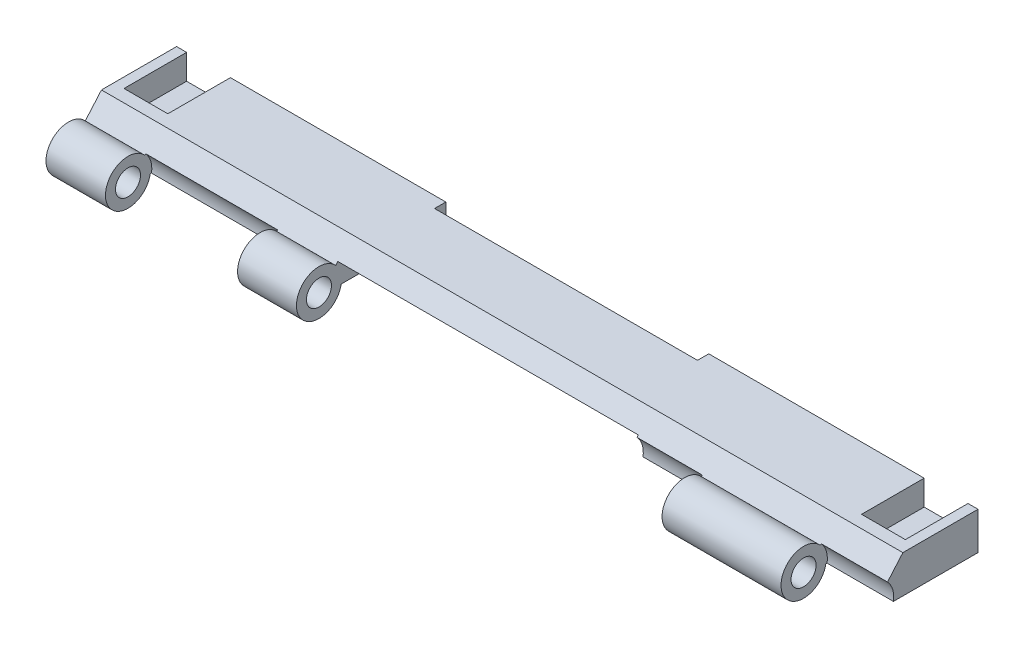
from build123d import *

# Parameters (mm, degrees)
SKETCH1_R                = 1.6002
SKETCH1_R_2              = 0.8128
BOSS_EXTRUDE5_DEPTH      = 162.56
CUT_EXTRUDE1_DEPTH       = 14.351
SKETCH3_W                = 0.889
SKETCH3_H                = 5.842
BOSS_EXTRUDE6_DEPTH      = 36.957
SKETCH16_W               = 13.462
SKETCH16_H               = 6.460130881
BOSS_EXTRUDE7_DEPTH      = 33.02
CUT_EXTRUDE4_DEPTH       = 15.24
SKETCH18_W               = 1.778
SKETCH18_H               = 5.842
BOSS_EXTRUDE8_DEPTH      = 38.1
CUT_EXTRUDE5_DEPTH       = 14.224
SKETCH20_W               = 2.1336
SKETCH20_H               = 5.461
BOSS_EXTRUDE9_DEPTH      = 36.322
SKETCH22_R               = 1.4224
CUT_EXTRUDE7_DEPTH       = 20.32
CUT_EXTRUDE7_DEPTH_BACK  = 24.13
SKETCH25_W               = 112.268
SKETCH25_H               = 3.007323321
CUT_EXTRUDE8_DEPTH       = 24.13
SKETCH27_R               = 1.778
CUT_EXTRUDE9_DEPTH       = 112.268
CUT_EXTRUDE12_DEPTH      = 14.224
SKETCH34_W               = 43.053
SKETCH34_H               = 2.1336
BOSS_EXTRUDE14_DEPTH     = 7.112
SKETCH35_R               = 1.4224
CUT_EXTRUDE13_DEPTH      = 7.112
SKETCH37_W               = 60.96
SKETCH37_H               = 15.24
CUT_EXTRUDE14_DEPTH      = 3.048
SKETCH38_R               = 0.8128
CUT_EXTRUDE15_DEPTH      = 5.08
SKETCH39_R               = 0.8128
CUT_EXTRUDE16_DEPTH      = 5.08
SKETCH40_W               = 60.96
SKETCH40_H               = 2.54
CUT_EXTRUDE17_DEPTH      = 3.048
SKETCH41_R               = 1.161307013
BOSS_EXTRUDE15_DEPTH     = 6.604
SKETCH42_R               = 1.020818471
BOSS_EXTRUDE16_DEPTH     = 5.588
SKETCH43_R               = 0.8128
CUT_EXTRUDE18_DEPTH      = 5.08
SKETCH44_R               = 0.8128
CUT_EXTRUDE19_DEPTH      = 5.08
SKETCH46_W               = 60.96
SKETCH46_H               = 9.087986699
CUT_EXTRUDE21_DEPTH      = 3.048
SKETCH47_W               = 53.34
SKETCH47_H               = 2.286
CUT_EXTRUDE22_DEPTH      = 15.24
SKETCH48_R               = 2.54
BOSS_EXTRUDE17_DEPTH     = 25.146
SKETCH49_R               = 2.54
BOSS_EXTRUDE18_DEPTH     = 25.146
SKETCH50_R               = 2.794
CUT_EXTRUDE23_DEPTH      = 112.268
SKETCH51_R               = 1.27
CUT_EXTRUDE24_DEPTH      = 174.498
CUT_EXTRUDE25_DEPTH      = 1.27
SKETCH55_W               = 46.703523857
SKETCH55_H               = 5.873481267
CUT_EXTRUDE26_DEPTH      = 9.144
CUT_EXTRUDE26_DEPTH_BACK = 8.636
SKETCH57_R               = 1.029255476
BOSS_EXTRUDE20_DEPTH     = 5.08
SKETCH58_R               = 1.09273592
BOSS_EXTRUDE21_DEPTH     = 7.112
SKETCH59_R               = 1.016
CUT_EXTRUDE27_DEPTH      = 66.04
CUT_EXTRUDE27_DEPTH_BACK = 5.08
SKETCH60_R               = 1.869467668
SKETCH60_R_2             = 1.016
BOSS_EXTRUDE22_DEPTH     = 162.56
SKETCH61_R               = 2.219373527
CUT_EXTRUDE28_DEPTH      = 112.268
SKETCH62_R               = 1.016
BOSS_EXTRUDE26_DEPTH     = 25.654
SKETCH65_R               = 1.016
BOSS_EXTRUDE27_DEPTH     = 25.654
SKETCH67_R               = 2.794
CUT_EXTRUDE32_DEPTH      = 12.827
SKETCH68_R               = 2.794
CUT_EXTRUDE33_DEPTH      = 12.827
SKETCH72_R               = 2.794
CUT_EXTRUDE34_DEPTH      = 25.654
BOSS_EXTRUDE28_DEPTH     = 0.127
SKETCH77_R               = 1.016
BOSS_EXTRUDE29_DEPTH     = 0.254
SKETCH79_R               = 1.016
CUT_EXTRUDE35_DEPTH      = 15.748
SKETCH87_W               = 23.622
SKETCH87_H               = 13.462
BOSS_EXTRUDE30_DEPTH     = 6.096
CUT_EXTRUDE36_DEPTH      = 14.9098
SKETCH89_W               = 1.4478
SKETCH89_H               = 6.35
BOSS_EXTRUDE31_DEPTH     = 30.6578
BOSS_EXTRUDE32_DEPTH     = 2.159
BOSS_EXTRUDE33_DEPTH     = 2.159
CUT_EXTRUDE38_DEPTH      = 43.053
BOSS_EXTRUDE35_DEPTH     = 14.859
SKETCH98_W               = 13.462
SKETCH98_H               = 6.35
CUT_EXTRUDE41_DEPTH      = 19.431
BOSS_EXTRUDE36_DEPTH     = 15.113
SKETCH102_W              = 13.462
SKETCH102_H              = 6.35
CUT_EXTRUDE42_DEPTH      = 27.051
BOSS_EXTRUDE39_DEPTH     = 2.159
BOSS_EXTRUDE40_DEPTH     = 14.986
BOSS_EXTRUDE41_DEPTH     = 2.159
SKETCH107_R              = 5.08
CUT_EXTRUDE43_DEPTH      = 173.736
SKETCH108_R              = 4.572
SKETCH108_R_2            = 2.54
BOSS_EXTRUDE43_DEPTH     = 162.56
SKETCH111_R              = 5.08
CUT_EXTRUDE44_DEPTH      = 60.96
SKETCH112_R              = 4.826
CUT_EXTRUDE45_DEPTH      = 13.462
SKETCH114_R              = 4.826
CUT_EXTRUDE46_DEPTH      = 26.797
SKETCH116_R              = 4.826
CUT_EXTRUDE47_DEPTH      = 13.208
SKETCH125_R              = 1.016
BOSS_EXTRUDE44_DEPTH     = 8.001
SKETCH126_R              = 1.016
BOSS_EXTRUDE45_DEPTH     = 7.747
SKETCH127_W              = 43.18
SKETCH127_H              = 1.27
BOSS_EXTRUDE46_DEPTH     = 1.27
SKETCH129_W              = 13.462
SKETCH129_H              = 6.35
BOSS_EXTRUDE47_DEPTH     = 47.244
SKETCH130_W              = 12.904618135
SKETCH130_H              = 7.62
BOSS_EXTRUDE48_DEPTH     = 46.482
SKETCH131_W              = 8.89
SKETCH131_H              = 12.7
CUT_EXTRUDE48_DEPTH      = 5.08


with BuildPart() as part:
    # Sketch1 → Boss-Extrude5 (new body)
    with BuildSketch(Plane(origin=(0, 0, 0), x_dir=(0, 0, -1), z_dir=(1, 0, 0))):
        with BuildLine():
            ThreePointArc((11.4584801, -1.874600251), (11.409460099, -2.267640517), (11.265403421, -2.636600251))
            Line((11.265403421, -2.636600251), (11.4584801, -2.636600251))
            Line((11.4584801, -2.636600251), (31.7784801, -2.636600251))
            Line((31.7784801, -2.636600251), (31.7784801, 4.983399749))
            Line((31.7784801, 4.983399749), (16.5384801, 4.983399749))
            Line((16.5384801, 4.983399749), (11.265403421, -1.112600251))
            ThreePointArc((11.265403421, -1.112600251), (11.409460099, -1.481559985), (11.4584801, -1.874600251))
        make_face()
        with Locations((9.8582801, -1.874600251)):
            Circle(SKETCH1_R)
        with Locations((9.8582801, -1.874600251)):
            Circle(SKETCH1_R_2, mode=Mode.SUBTRACT)
    extrude(amount=BOSS_EXTRUDE5_DEPTH)

    # Sketch2 → Cut-Extrude1 (cut)
    with BuildSketch(Plane(origin=(0, 0, -31.7784801), x_dir=(-1, 0, 0), z_dir=(0, 0, -1))):
        Polygon((0, 4.983399749), (0, -0.858600251), (-17.78, -0.858600251), (-23.622, 4.983399749), align=None)
    extrude(amount=-CUT_EXTRUDE1_DEPTH, mode=Mode.SUBTRACT)

    # Sketch3 → Boss-Extrude6 (add)
    with BuildSketch(Plane.ZY):
        with Locations((-31.3339801, 2.062399749)):
            Rectangle(SKETCH3_W, SKETCH3_H)
    extrude(amount=-BOSS_EXTRUDE6_DEPTH)

    # Sketch16 → Boss-Extrude7 (add)
    with BuildSketch(Plane.ZY):
        with Locations((-24.1584801, 1.753334308)):
            Rectangle(SKETCH16_W, SKETCH16_H)
    extrude(amount=-BOSS_EXTRUDE7_DEPTH)

    # Sketch17 → Cut-Extrude4 (cut)
    with BuildSketch(Plane(origin=(0, 0, -31.7784801), x_dir=(-1, 0, 0), z_dir=(0, 0, -1))):
        Polygon((0, 4.983399749), (0, -0.858600251), (-17.78, -0.858600251), (-23.622, 4.983399749), align=None)
    extrude(amount=-CUT_EXTRUDE4_DEPTH, mode=Mode.SUBTRACT)

    # Sketch18 → Boss-Extrude8 (add)
    with BuildSketch(Plane.ZY):
        with Locations((-30.8894801, 2.062399749)):
            Rectangle(SKETCH18_W, SKETCH18_H)
    extrude(amount=-BOSS_EXTRUDE8_DEPTH)

    # Sketch19 → Cut-Extrude5 (cut)
    with BuildSketch(Plane(origin=(0, 0, -31.7784801), x_dir=(-1, 0, 0), z_dir=(0, 0, -1))):
        Polygon((-162.56, 4.983399749), (-162.56, -0.477600251), (-142.24, -0.477600251), (-136.779, 4.983399749), align=None)
    extrude(amount=-CUT_EXTRUDE5_DEPTH, mode=Mode.SUBTRACT)

    # Sketch20 → Boss-Extrude9 (add)
    with BuildSketch(Plane(origin=(162.56, 0, 0), x_dir=(0, 0, -1), z_dir=(1, 0, 0))):
        with Locations((30.7116801, 2.252899749)):
            Rectangle(SKETCH20_W, SKETCH20_H)
    extrude(amount=-BOSS_EXTRUDE9_DEPTH)

    # Sketch22 → Cut-Extrude7 (cut, two sides)
    with BuildSketch(Plane(origin=(0, -0.477600251, 0), x_dir=(1, 0, 0), z_dir=(0, 1, 0))) as cut_extrude7_sk:
        with Locations((145.9484, 26.5714801)):
            Circle(SKETCH22_R)
        with BuildLine():
            ThreePointArc((147.3708, 26.5714801), (146.954188686, 25.565691415), (145.9484, 25.1490801))
            Line((145.9484, 25.1490801), (157.217057139, 25.1490801))
            ThreePointArc((157.217057139, 25.1490801), (155.794657139, 26.5714801), (157.217057139, 27.9938801))
            Line((157.217057139, 27.9938801), (145.9484, 27.9938801))
            ThreePointArc((145.9484, 27.9938801), (146.954188686, 27.577268786), (147.3708, 26.5714801))
        make_face()
        with Locations((157.217057139, 26.5714801)):
            Circle(SKETCH22_R)
        with BuildLine():
            ThreePointArc((157.217057139, 19.1292801), (155.794657139, 20.5516801), (157.217057139, 21.9740801))
            Line((157.217057139, 21.9740801), (145.9484, 21.9740801))
            ThreePointArc((145.9484, 21.9740801), (146.954188686, 21.557468786), (147.3708, 20.5516801))
            ThreePointArc((147.3708, 20.5516801), (146.954188686, 19.545891415), (145.9484, 19.1292801))
            Line((145.9484, 19.1292801), (157.217057139, 19.1292801))
        make_face()
        with Locations((157.217057139, 20.5516801)):
            Circle(SKETCH22_R)
        with Locations((145.9484, 20.5516801)):
            Circle(SKETCH22_R)
    extrude(amount=CUT_EXTRUDE7_DEPTH, mode=Mode.SUBTRACT)
    extrude(cut_extrude7_sk.sketch, amount=-CUT_EXTRUDE7_DEPTH_BACK, mode=Mode.SUBTRACT)

    # Sketch25 → Cut-Extrude8 (cut)
    with BuildSketch(Plane(origin=(0, 4.983399749, 0), x_dir=(1, 0, 0), z_dir=(0, 1, 0))):
        with Locations((81.28, 9.761741761)):
            Rectangle(SKETCH25_W, SKETCH25_H)
    extrude(amount=-CUT_EXTRUDE8_DEPTH, mode=Mode.SUBTRACT)

    # Sketch27 → Cut-Extrude9 (cut)
    with BuildSketch(Plane.ZY.offset(-137.414)):
        with Locations((-9.8582801, -1.874600251)):
            Circle(SKETCH27_R)
    extrude(amount=CUT_EXTRUDE9_DEPTH, mode=Mode.SUBTRACT)

    # Sketch31 → Cut-Extrude12 (cut)
    with BuildSketch(Plane(origin=(0, 0, -31.7784801), x_dir=(-1, 0, 0), z_dir=(0, 0, -1))):
        Polygon((-162.56, 4.983399749), (-162.56, -0.477600251), (-124.968, -0.477600251), (-119.507, 4.983399749), (-124.079, 4.983399749), align=None)
    extrude(amount=-CUT_EXTRUDE12_DEPTH, mode=Mode.SUBTRACT)

    # Sketch34 → Boss-Extrude14 (add)
    with BuildSketch(Plane(origin=(0, 4.983399749, 0), x_dir=(1, 0, 0), z_dir=(0, 1, 0))):
        with Locations((141.0335, 30.7116801)):
            Rectangle(SKETCH34_W, SKETCH34_H)
    extrude(amount=-BOSS_EXTRUDE14_DEPTH)

    # Sketch35 → Cut-Extrude13 (cut)
    with BuildSketch(Plane(origin=(0, -0.477600251, 0), x_dir=(1, 0, 0), z_dir=(0, 1, 0))):
        with BuildLine():
            Line((130.048, 25.1490801), (145.9484, 25.1490801))
            ThreePointArc((145.9484, 25.1490801), (144.526, 26.5714801), (145.9484, 27.9938801))
            Line((145.9484, 27.9938801), (130.048, 27.9938801))
            ThreePointArc((130.048, 27.9938801), (131.053788686, 27.577268786), (131.4704, 26.5714801))
            ThreePointArc((131.4704, 26.5714801), (131.053788686, 25.565691415), (130.048, 25.1490801))
        make_face()
        with BuildLine():
            ThreePointArc((145.9484, 19.1292801), (144.526, 20.5516801), (145.9484, 21.9740801))
            Line((145.9484, 21.9740801), (130.048, 21.9740801))
            ThreePointArc((130.048, 21.9740801), (131.053788686, 21.557468786), (131.4704, 20.5516801))
            ThreePointArc((131.4704, 20.5516801), (131.053788686, 19.545891415), (130.048, 19.1292801))
            Line((130.048, 19.1292801), (145.9484, 19.1292801))
        make_face()
        with Locations((130.048, 20.5516801)):
            Circle(SKETCH35_R)
        with Locations((130.048, 26.5714801)):
            Circle(SKETCH35_R)
    extrude(amount=-CUT_EXTRUDE13_DEPTH, mode=Mode.SUBTRACT)

    # Sketch37 → Cut-Extrude14 (cut)
    with BuildSketch(Plane(origin=(0, -2.636600251, 0), x_dir=(-1, 0, 0), z_dir=(0, -1, 0))):
        with Locations((-81.28, 21.6184801)):
            Rectangle(SKETCH37_W, SKETCH37_H)
    extrude(amount=-CUT_EXTRUDE14_DEPTH, mode=Mode.SUBTRACT)

    # Sketch38 → Cut-Extrude15 (cut)
    with BuildSketch(Plane.ZY.offset(-111.76)):
        with Locations((-27.9684801, -1.112600251)):
            Circle(SKETCH38_R)
    extrude(amount=-CUT_EXTRUDE15_DEPTH, mode=Mode.SUBTRACT)

    # Sketch39 → Cut-Extrude16 (cut)
    with BuildSketch(Plane(origin=(50.8, 0, 0), x_dir=(0, 0, -1), z_dir=(1, 0, 0))):
        with Locations(Location((27.9684801, -1.112600251, 0), (0, 0, 180))):
            Circle(SKETCH39_R)
    extrude(amount=-CUT_EXTRUDE16_DEPTH, mode=Mode.SUBTRACT)

    # Sketch40 → Cut-Extrude17 (cut)
    with BuildSketch(Plane(origin=(0, -2.636600251, 0), x_dir=(-1, 0, 0), z_dir=(0, -1, 0))):
        with Locations((-81.28, 30.5084801)):
            Rectangle(SKETCH40_W, SKETCH40_H)
    extrude(amount=-CUT_EXTRUDE17_DEPTH, mode=Mode.SUBTRACT)

    # Sketch41 → Boss-Extrude15 (add)
    with BuildSketch(Plane(origin=(50.8, 0, 0), x_dir=(0, 0, -1), z_dir=(1, 0, 0))):
        with Locations((27.9684801, -1.112600251)):
            Circle(SKETCH41_R)
    extrude(amount=-BOSS_EXTRUDE15_DEPTH)

    # Sketch42 → Boss-Extrude16 (add)
    with BuildSketch(Plane.ZY.offset(-111.76)):
        with Locations((-27.9684801, -1.112600251)):
            Circle(SKETCH42_R)
    extrude(amount=-BOSS_EXTRUDE16_DEPTH)

    # Sketch43 → Cut-Extrude18 (cut)
    with BuildSketch(Plane(origin=(50.8, 0, 0), x_dir=(0, 0, -1), z_dir=(1, 0, 0))):
        with Locations((30.5084801, -1.112600251)):
            Circle(SKETCH43_R)
    extrude(amount=-CUT_EXTRUDE18_DEPTH, mode=Mode.SUBTRACT)

    # Sketch44 → Cut-Extrude19 (cut)
    with BuildSketch(Plane.ZY.offset(-111.76)):
        with Locations(Location((-30.5084801, -1.112600251, 0), (0, 0, 180))):
            Circle(SKETCH44_R)
    extrude(amount=-CUT_EXTRUDE19_DEPTH, mode=Mode.SUBTRACT)

    # Sketch46 → Cut-Extrude21 (cut)
    with BuildSketch(Plane(origin=(0, -2.636600251, 0), x_dir=(-1, 0, 0), z_dir=(0, -1, 0))):
        with Locations((-81.28, 9.45448675)):
            Rectangle(SKETCH46_W, SKETCH46_H)
    extrude(amount=-CUT_EXTRUDE21_DEPTH, mode=Mode.SUBTRACT)

    # Sketch47 → Cut-Extrude22 (cut)
    with BuildSketch(Plane(origin=(0, 0.411399749, 0), x_dir=(-1, 0, 0), z_dir=(0, -1, 0))):
        with Locations((-81.28, 30.6354801)):
            Rectangle(SKETCH47_W, SKETCH47_H)
    extrude(amount=-CUT_EXTRUDE22_DEPTH, mode=Mode.SUBTRACT)

    # Sketch48 → Boss-Extrude17 (add)
    with BuildSketch(Plane.ZY):
        with Locations((-9.8582801, -1.874600251)):
            Circle(SKETCH48_R)
    extrude(amount=-BOSS_EXTRUDE17_DEPTH)

    # Sketch49 → Boss-Extrude18 (add)
    with BuildSketch(Plane(origin=(162.56, 0, 0), x_dir=(0, 0, -1), z_dir=(1, 0, 0))):
        with Locations((9.8582801, -1.874600251)):
            Circle(SKETCH49_R)
    extrude(amount=-BOSS_EXTRUDE18_DEPTH)

    # Sketch50 → Cut-Extrude23 (cut)
    with BuildSketch(Plane.ZY.offset(-137.414)):
        with Locations((-9.8582801, -1.874600251)):
            Circle(SKETCH50_R)
    extrude(amount=CUT_EXTRUDE23_DEPTH, mode=Mode.SUBTRACT)

    # Sketch51 → Cut-Extrude24 (cut)
    with BuildSketch(Plane(origin=(162.56, 0, 0), x_dir=(0, 0, -1), z_dir=(1, 0, 0))):
        with Locations((9.8582801, -1.874600251)):
            Circle(SKETCH51_R)
    extrude(amount=-CUT_EXTRUDE24_DEPTH, mode=Mode.SUBTRACT)

    # Sketch52 → Cut-Extrude25 (cut)
    with BuildSketch(Plane(origin=(0, 0.411399749, 0), x_dir=(-1, 0, 0), z_dir=(0, -1, 0))):
        Polygon((-50.8, 31.7784801), (-50.8, 12.546363432), (-111.76, 12.6522801), (-111.76, 31.7784801), align=None)
    extrude(amount=-CUT_EXTRUDE25_DEPTH, mode=Mode.SUBTRACT)

    # Sketch55 → Cut-Extrude26 (cut, two sides)
    with BuildSketch(Plane.XZ.offset(2.636600251)) as cut_extrude26_sk:
        with Locations((88.408238071, -10.745489599)):
            Rectangle(SKETCH55_W, SKETCH55_H)
    extrude(amount=CUT_EXTRUDE26_DEPTH, mode=Mode.SUBTRACT)
    extrude(cut_extrude26_sk.sketch, amount=-CUT_EXTRUDE26_DEPTH_BACK, mode=Mode.SUBTRACT)

    # Sketch57 → Boss-Extrude20 (add)
    with BuildSketch(Plane(origin=(45.72, 0, 0), x_dir=(0, 0, -1), z_dir=(1, 0, 0))):
        with Locations((30.5084801, -1.112600251)):
            Circle(SKETCH57_R)
    extrude(amount=BOSS_EXTRUDE20_DEPTH)

    # Sketch58 → Boss-Extrude21 (add)
    with BuildSketch(Plane.ZY.offset(-111.76)):
        with Locations((-30.5084801, -1.112600251)):
            Circle(SKETCH58_R)
    extrude(amount=-BOSS_EXTRUDE21_DEPTH)

    # Sketch59 → Cut-Extrude27 (cut, two sides)
    with BuildSketch(Plane(origin=(50.8, 0, 0), x_dir=(0, 0, -1), z_dir=(1, 0, 0))) as cut_extrude27_sk:
        with Locations((29.2384801, -0.477600251)):
            Circle(SKETCH59_R)
    extrude(amount=CUT_EXTRUDE27_DEPTH, mode=Mode.SUBTRACT)
    extrude(cut_extrude27_sk.sketch, amount=-CUT_EXTRUDE27_DEPTH_BACK, mode=Mode.SUBTRACT)

    # Sketch60 → Boss-Extrude22 (add)
    with BuildSketch(Plane.ZY):
        with Locations((-9.8582801, -1.874600251)):
            Circle(SKETCH60_R)
        with Locations((-9.8582801, -1.874600251)):
            Circle(SKETCH60_R_2, mode=Mode.SUBTRACT)
    extrude(amount=-BOSS_EXTRUDE22_DEPTH)

    # Sketch61 → Cut-Extrude28 (cut)
    with BuildSketch(Plane.ZY.offset(-137.414)):
        with Locations((-9.8582801, -1.874600251)):
            Circle(SKETCH61_R)
    extrude(amount=CUT_EXTRUDE28_DEPTH, mode=Mode.SUBTRACT)

    # Sketch62 → Boss-Extrude26 (add)
    with BuildSketch(Plane(origin=(25.146, 0, 0), x_dir=(0, 0, -1), z_dir=(1, 0, 0))):
        with BuildLine():
            Line((12.07614536, -0.175332853), (11.906096413, -0.371919863))
            ThreePointArc((11.906096413, -0.371919863), (12.272100043, -1.083984489), (12.3982801, -1.874600251))
            ThreePointArc((12.3982801, -1.874600251), (12.368861124, -2.260064807), (12.281285672, -2.636600251))
            Line((12.281285672, -2.636600251), (12.546363432, -2.636600251))
            ThreePointArc((12.546363432, -2.636600251), (12.602645637, -1.350297092), (12.07614536, -0.175332853))
        make_face()
        with BuildLine():
            ThreePointArc((12.3982801, -1.874600251), (12.272100043, -1.083984489), (11.906096413, -0.371919863))
            ThreePointArc((11.906096413, -0.371919863), (7.352435653, -2.289743123), (12.281285672, -2.636600251))
            ThreePointArc((12.281285672, -2.636600251), (12.368861124, -2.260064807), (12.3982801, -1.874600251))
        make_face()
        with Locations(Location((9.8582801, -1.874600251, 0), (0, 0, 180))):
            Circle(SKETCH62_R, mode=Mode.SUBTRACT)
    extrude(amount=BOSS_EXTRUDE26_DEPTH)

    # Sketch65 → Boss-Extrude27 (add)
    with BuildSketch(Plane.ZY.offset(-137.414)):
        with BuildLine():
            ThreePointArc((-12.281285672, -2.636600251), (-12.364124548, -1.459457379), (-11.906096413, -0.371919863))
            Line((-11.906096413, -0.371919863), (-12.07614536, -0.175332853))
            ThreePointArc((-12.07614536, -0.175332853), (-12.602645637, -1.350297092), (-12.546363432, -2.636600251))
            Line((-12.546363432, -2.636600251), (-12.281285672, -2.636600251))
        make_face()
        with BuildLine():
            ThreePointArc((-7.3182801, -1.874600251), (-9.067664339, 0.539219692), (-11.906096413, -0.371919863))
            ThreePointArc((-11.906096413, -0.371919863), (-12.364124548, -1.459457379), (-12.281285672, -2.636600251))
            ThreePointArc((-12.281285672, -2.636600251), (-9.472815544, -4.385181275), (-7.3182801, -1.874600251))
        make_face()
        with Locations((-9.8582801, -1.874600251)):
            Circle(SKETCH65_R, mode=Mode.SUBTRACT)
    extrude(amount=BOSS_EXTRUDE27_DEPTH)

    # Sketch67 → Cut-Extrude32 (cut)
    with BuildSketch(Plane(origin=(162.56, 0, 0), x_dir=(0, 0, -1), z_dir=(1, 0, 0))):
        with Locations((9.8582801, -1.874600251)):
            Circle(SKETCH67_R)
    extrude(amount=-CUT_EXTRUDE32_DEPTH, mode=Mode.SUBTRACT)

    # Sketch68 → Cut-Extrude33 (cut)
    with BuildSketch(Plane.ZY.offset(-111.76)):
        with Locations((-9.8582801, -1.874600251)):
            Circle(SKETCH68_R)
    extrude(amount=-CUT_EXTRUDE33_DEPTH, mode=Mode.SUBTRACT)

    # Sketch72 → Cut-Extrude34 (cut)
    with BuildSketch(Plane.ZY.offset(-12.573)):
        with Locations((-9.8582801, -1.874600251)):
            Circle(SKETCH72_R)
    extrude(amount=-CUT_EXTRUDE34_DEPTH, mode=Mode.SUBTRACT)

    # Sketch74 → Boss-Extrude28 (add)
    with BuildSketch(Plane.ZY.offset(-12.573)):
        with BuildLine():
            Line((-12.546363432, -2.636600251), (-12.281285672, -2.636600251))
            ThreePointArc((-12.281285672, -2.636600251), (-7.352435653, -2.289743123), (-11.906096413, -0.371919863))
            Line((-11.906096413, -0.371919863), (-12.07614536, -0.175332853))
            ThreePointArc((-12.07614536, -0.175332853), (-12.602645637, -1.350297092), (-12.546363432, -2.636600251))
        make_face()
    extrude(amount=-BOSS_EXTRUDE28_DEPTH)

    # Sketch77 → Boss-Extrude29 (add)
    with BuildSketch(Plane.ZY.offset(-124.587)):
        with BuildLine():
            ThreePointArc((-11.906096413, -0.371919863), (-12.364124548, -1.459457379), (-12.281285672, -2.636600251))
            ThreePointArc((-12.281285672, -2.636600251), (-9.472815544, -4.385181275), (-7.3182801, -1.874600251))
            ThreePointArc((-7.3182801, -1.874600251), (-9.067664339, 0.539219692), (-11.906096413, -0.371919863))
        make_face()
        with Locations((-9.8582801, -1.874600251)):
            Circle(SKETCH77_R, mode=Mode.SUBTRACT)
        with BuildLine():
            Line((-12.546363432, -2.636600251), (-12.281285672, -2.636600251))
            ThreePointArc((-12.281285672, -2.636600251), (-12.364124548, -1.459457379), (-11.906096413, -0.371919863))
            Line((-11.906096413, -0.371919863), (-12.07614536, -0.175332853))
            ThreePointArc((-12.07614536, -0.175332853), (-12.602645637, -1.350297092), (-12.546363432, -2.636600251))
        make_face()
    extrude(amount=BOSS_EXTRUDE29_DEPTH)

    # Sketch79 → Cut-Extrude35 (cut)
    with BuildSketch(Plane.ZY):
        with Locations((-9.8582801, -1.874600251)):
            Circle(SKETCH79_R)
    extrude(amount=-CUT_EXTRUDE35_DEPTH, mode=Mode.SUBTRACT)

    # Sketch87 → Boss-Extrude30 (add)
    with BuildSketch(Plane(origin=(0, 4.983399749, 0), x_dir=(1, 0, 0), z_dir=(0, 1, 0))):
        with Locations((11.811, 23.2694801)):
            Rectangle(SKETCH87_W, SKETCH87_H)
    extrude(amount=-BOSS_EXTRUDE30_DEPTH)

    # Sketch88 → Cut-Extrude36 (cut)
    with BuildSketch(Plane(origin=(0, 0, -31.7784801), x_dir=(-1, 0, 0), z_dir=(0, 0, -1))):
        Polygon((0, 4.983399749), (0, -1.366600251), (-17.78, -1.366600251), (-23.622, 4.983399749), align=None)
    extrude(amount=-CUT_EXTRUDE36_DEPTH, mode=Mode.SUBTRACT)

    # Sketch89 → Boss-Extrude31 (add)
    with BuildSketch(Plane.ZY):
        with Locations((-31.0545801, 1.808399749)):
            Rectangle(SKETCH89_W, SKETCH89_H)
    extrude(amount=-BOSS_EXTRUDE31_DEPTH)

    # Sketch90 → Boss-Extrude32 (add)
    with BuildSketch(Plane(origin=(0, -2.636600251, 0), x_dir=(-1, 0, 0), z_dir=(0, -1, 0))):
        with BuildLine():
            Line((-130.048, 27.9938801), (-137.16, 27.9938801))
            ThreePointArc((-137.16, 27.9938801), (-136.154211314, 27.577268786), (-135.7376, 26.5714801))
            ThreePointArc((-135.7376, 26.5714801), (-136.154211314, 25.565691415), (-137.16, 25.1490801))
            Line((-137.16, 25.1490801), (-130.048, 25.1490801))
            ThreePointArc((-130.048, 25.1490801), (-128.6256, 26.5714801), (-130.048, 27.9938801))
        make_face()
        with BuildLine():
            ThreePointArc((-135.7376, 20.5516801), (-136.154211314, 19.545891415), (-137.16, 19.1292801))
            Line((-137.16, 19.1292801), (-130.048, 19.1292801))
            ThreePointArc((-130.048, 19.1292801), (-128.6256, 20.5516801), (-130.048, 21.9740801))
            Line((-130.048, 21.9740801), (-137.16, 21.9740801))
            ThreePointArc((-137.16, 21.9740801), (-136.154211314, 21.557468786), (-135.7376, 20.5516801))
        make_face()
    extrude(amount=-BOSS_EXTRUDE32_DEPTH)

    # Sketch91 → Boss-Extrude33 (add)
    with BuildSketch(Plane(origin=(0, -2.636600251, 0), x_dir=(-1, 0, 0), z_dir=(0, -1, 0))):
        with BuildLine():
            Line((-156.251857139, 26.5714801), (-158.639457139, 26.5714801))
            ThreePointArc((-158.639457139, 26.5714801), (-158.222845825, 25.565691415), (-157.217057139, 25.1490801))
            Line((-157.217057139, 25.1490801), (-154.829457139, 25.1490801))
            ThreePointArc((-154.829457139, 25.1490801), (-155.835245825, 25.565691415), (-156.251857139, 26.5714801))
        make_face()
        with BuildLine():
            ThreePointArc((-157.217057139, 27.9938801), (-158.222845825, 27.577268786), (-158.639457139, 26.5714801))
            Line((-158.639457139, 26.5714801), (-156.251857139, 26.5714801))
            ThreePointArc((-156.251857139, 26.5714801), (-155.835245825, 27.577268786), (-154.829457139, 27.9938801))
            Line((-154.829457139, 27.9938801), (-157.217057139, 27.9938801))
        make_face()
        with BuildLine():
            ThreePointArc((-157.217057139, 21.9740801), (-158.222845825, 21.557468786), (-158.639457139, 20.5516801))
            Line((-158.639457139, 20.5516801), (-156.251857139, 20.5516801))
            ThreePointArc((-156.251857139, 20.5516801), (-155.835245825, 21.557468786), (-154.829457139, 21.9740801))
            Line((-154.829457139, 21.9740801), (-157.217057139, 21.9740801))
        make_face()
        with BuildLine():
            Line((-156.251857139, 20.5516801), (-158.639457139, 20.5516801))
            ThreePointArc((-158.639457139, 20.5516801), (-158.222845825, 19.545891415), (-157.217057139, 19.1292801))
            Line((-157.217057139, 19.1292801), (-154.829457139, 19.1292801))
            ThreePointArc((-154.829457139, 19.1292801), (-155.835245825, 19.545891415), (-156.251857139, 20.5516801))
        make_face()
    extrude(amount=-BOSS_EXTRUDE33_DEPTH)

    # Sketch92 → Cut-Extrude38 (cut)
    with BuildSketch(Plane(origin=(162.56, 0, 0), x_dir=(0, 0, -1), z_dir=(1, 0, 0))):
        Polygon((29.6448801, -0.477600251), (29.8988801, -0.477600251), (29.8988801, 4.983399749), (17.3004801, 4.983399749), (17.3004801, -0.477600251), align=None)
    extrude(amount=-CUT_EXTRUDE38_DEPTH, mode=Mode.SUBTRACT)

    # Sketch94 → Boss-Extrude35 (add)
    with BuildSketch(Plane(origin=(0, 0, -31.7784801), x_dir=(-1, 0, 0), z_dir=(0, 0, -1))):
        Polygon((-119.507, 4.983399749), (-124.968, -0.477600251), (-119.507, -0.477600251), align=None)
    extrude(amount=-BOSS_EXTRUDE35_DEPTH)

    # Sketch98 → Cut-Extrude41 (cut)
    with BuildSketch(Plane.ZY.offset(-23.622)):
        with Locations((-23.5996801, 1.808399749)):
            Rectangle(SKETCH98_W, SKETCH98_H)
    extrude(amount=-CUT_EXTRUDE41_DEPTH, mode=Mode.SUBTRACT)

    # Sketch101 → Boss-Extrude36 (add)
    with BuildSketch(Plane(origin=(0, 0, -31.7784801), x_dir=(-1, 0, 0), z_dir=(0, 0, -1))):
        Polygon((-43.053, 4.983399749), (-37.592, -0.477600251), (-43.053, -0.477600251), align=None)
    extrude(amount=-BOSS_EXTRUDE36_DEPTH)

    # Sketch102 → Cut-Extrude42 (cut)
    with BuildSketch(Plane.ZY):
        with Locations((-23.5996801, 1.808399749)):
            Rectangle(SKETCH102_W, SKETCH102_H)
    extrude(amount=-CUT_EXTRUDE42_DEPTH, mode=Mode.SUBTRACT)

    # Sketch103 → Boss-Extrude39 (add)
    with BuildSketch(Plane(origin=(0, -0.477600251, 0), x_dir=(1, 0, 0), z_dir=(0, 1, 0))):
        with BuildLine():
            ThreePointArc((137.7696, 26.5714801), (138.186211314, 27.577268786), (139.192, 27.9938801))
            Line((139.192, 27.9938801), (137.16, 27.9938801))
            ThreePointArc((137.16, 27.9938801), (135.7376, 26.5714801), (137.16, 25.1490801))
            Line((137.16, 25.1490801), (139.192, 25.1490801))
            ThreePointArc((139.192, 25.1490801), (138.186211314, 25.565691415), (137.7696, 26.5714801))
        make_face()
        with BuildLine():
            ThreePointArc((137.7696, 20.5516801), (138.186211314, 21.557468786), (139.192, 21.9740801))
            Line((139.192, 21.9740801), (137.16, 21.9740801))
            ThreePointArc((137.16, 21.9740801), (135.7376, 20.5516801), (137.16, 19.1292801))
            Line((137.16, 19.1292801), (139.192, 19.1292801))
            ThreePointArc((139.192, 19.1292801), (138.186211314, 19.545891415), (137.7696, 20.5516801))
        make_face()
    extrude(amount=-BOSS_EXTRUDE39_DEPTH)

    # Sketch105 → Boss-Extrude40 (add)
    with BuildSketch(Plane(origin=(0, 0, -31.7784801), x_dir=(-1, 0, 0), z_dir=(0, 0, -1))):
        Polygon((-43.053, 4.983399749), (-43.053, -2.200805148), (-35.868795103, -2.200805148), align=None)
    extrude(amount=-BOSS_EXTRUDE40_DEPTH)

    # Sketch106 → Boss-Extrude41 (add)
    with BuildSketch(Plane(origin=(0, -0.477600251, 0), x_dir=(1, 0, 0), z_dir=(0, 1, 0))):
        with BuildLine():
            ThreePointArc((154.432, 27.9938801), (155.437788686, 27.577268786), (155.8544, 26.5714801))
            ThreePointArc((155.8544, 26.5714801), (155.437788686, 25.565691415), (154.432, 25.1490801))
            Line((154.432, 25.1490801), (154.829457139, 25.1490801))
            ThreePointArc((154.829457139, 25.1490801), (156.251857139, 26.5714801), (154.829457139, 27.9938801))
            Line((154.829457139, 27.9938801), (154.432, 27.9938801))
        make_face()
        with BuildLine():
            ThreePointArc((154.432, 21.9740801), (155.437788686, 21.557468786), (155.8544, 20.5516801))
            ThreePointArc((155.8544, 20.5516801), (155.437788686, 19.545891415), (154.432, 19.1292801))
            Line((154.432, 19.1292801), (154.829457139, 19.1292801))
            ThreePointArc((154.829457139, 19.1292801), (156.251857139, 20.5516801), (154.829457139, 21.9740801))
            Line((154.829457139, 21.9740801), (154.432, 21.9740801))
        make_face()
    extrude(amount=-BOSS_EXTRUDE41_DEPTH)

    # Sketch107 → Cut-Extrude43 (cut)
    with BuildSketch(Plane(origin=(162.56, 0, 0), x_dir=(0, 0, -1), z_dir=(1, 0, 0))):
        with Locations((9.8582801, -1.874600251)):
            Circle(SKETCH107_R)
    extrude(amount=-CUT_EXTRUDE43_DEPTH, mode=Mode.SUBTRACT)

    # Sketch108 → Boss-Extrude43 (add)
    with BuildSketch(Plane.ZY):
        with BuildLine():
            Line((-13.25421048, 1.186582667), (-13.588864385, 1.573463104))
            ThreePointArc((-13.588864385, 1.573463104), (-14.714759103, -0.384294342), (-14.880804963, -2.636600251))
            Line((-14.880804963, -2.636600251), (-14.366332895, -2.636600251))
            ThreePointArc((-14.366332895, -2.636600251), (-14.24831648, -0.597586316), (-13.25421048, 1.186582667))
        make_face()
        with Locations((-9.8582801, -1.874600251)):
            Circle(SKETCH108_R)
        with Locations((-9.8582801, -1.874600251)):
            Circle(SKETCH108_R_2, mode=Mode.SUBTRACT)
    extrude(amount=-BOSS_EXTRUDE43_DEPTH)

    # Sketch111 → Cut-Extrude44 (cut)
    with BuildSketch(Plane(origin=(50.8, 0, 0), x_dir=(0, 0, -1), z_dir=(1, 0, 0))):
        with Locations((9.8582801, -1.874600251)):
            Circle(SKETCH111_R)
    extrude(amount=CUT_EXTRUDE44_DEPTH, mode=Mode.SUBTRACT)

    # Sketch112 → Cut-Extrude45 (cut)
    with BuildSketch(Plane(origin=(162.56, 0, 0), x_dir=(0, 0, -1), z_dir=(1, 0, 0))):
        with Locations((9.8582801, -1.874600251)):
            Circle(SKETCH112_R)
    extrude(amount=-CUT_EXTRUDE45_DEPTH, mode=Mode.SUBTRACT)

    # Sketch114 → Cut-Extrude46 (cut)
    with BuildSketch(Plane.ZY.offset(-12.065)):
        with Locations((-9.8582801, -1.874600251)):
            Circle(SKETCH114_R)
    extrude(amount=-CUT_EXTRUDE46_DEPTH, mode=Mode.SUBTRACT)

    # Sketch116 → Cut-Extrude47 (cut)
    with BuildSketch(Plane.ZY.offset(-111.76)):
        with Locations((-9.8582801, -1.874600251)):
            Circle(SKETCH116_R)
    extrude(amount=-CUT_EXTRUDE47_DEPTH, mode=Mode.SUBTRACT)

    # Sketch125 → Boss-Extrude44 (add)
    with BuildSketch(Plane.ZY.offset(-111.76)):
        with Locations((-29.2384801, -0.477600251)):
            Circle(SKETCH125_R)
    extrude(amount=-BOSS_EXTRUDE44_DEPTH)

    # Sketch126 → Boss-Extrude45 (add)
    with BuildSketch(Plane(origin=(50.8, 0, 0), x_dir=(0, 0, -1), z_dir=(1, 0, 0))):
        with Locations((29.2384801, -0.477600251)):
            Circle(SKETCH126_R)
    extrude(amount=-BOSS_EXTRUDE45_DEPTH)

    # Sketch127 → Boss-Extrude46 (add)
    with BuildSketch(Plane(origin=(0, 1.681399749, 0), x_dir=(-1, 0, 0), z_dir=(0, -1, 0))):
        with Locations((-81.28, 26.3174801)):
            Rectangle(SKETCH127_W, SKETCH127_H)
        with Locations((-81.28, 22.5074801)):
            Rectangle(SKETCH127_W, SKETCH127_H)
        with Locations((-81.28, 18.6974801)):
            Rectangle(SKETCH127_W, SKETCH127_H)
    extrude(amount=BOSS_EXTRUDE46_DEPTH)

    # Sketch129 → Boss-Extrude47 (add)
    with BuildSketch(Plane.ZY):
        with Locations((-23.5996801, 1.808399749)):
            Rectangle(SKETCH129_W, SKETCH129_H)
    extrude(amount=-BOSS_EXTRUDE47_DEPTH)

    # Sketch130 → Boss-Extrude48 (add)
    with BuildSketch(Plane(origin=(162.56, 0, 0), x_dir=(0, 0, -1), z_dir=(1, 0, 0))):
        with Locations((23.752789168, 1.173399749)):
            Rectangle(SKETCH130_W, SKETCH130_H)
    extrude(amount=-BOSS_EXTRUDE48_DEPTH)

    # Sketch131 → Cut-Extrude48 (cut)
    with BuildSketch(Plane(origin=(0, 4.983399749, 0), x_dir=(1, 0, 0), z_dir=(0, 1, 0))):
        with Locations((156.083, 25.4284801)):
            Rectangle(SKETCH131_W, SKETCH131_H)
        with Locations((6.477, 25.4284801)):
            Rectangle(SKETCH131_W, SKETCH131_H)
    extrude(amount=-CUT_EXTRUDE48_DEPTH, mode=Mode.SUBTRACT)


solid = part.part
